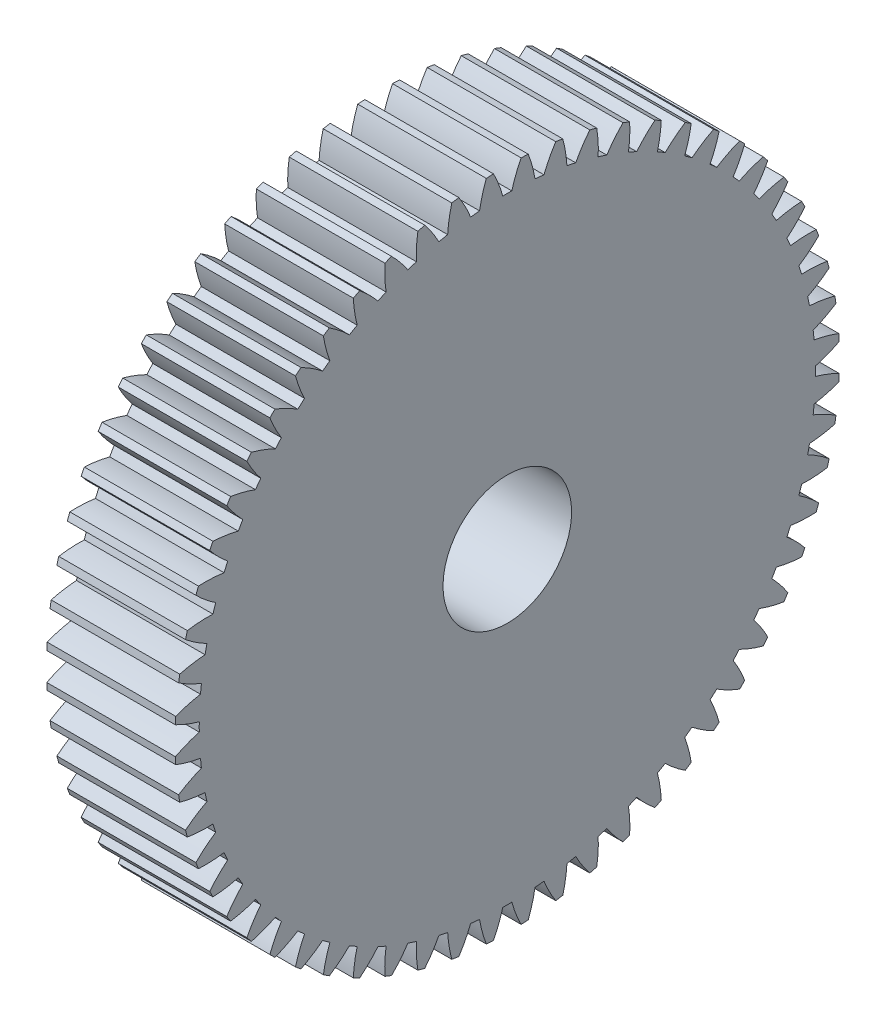
from build123d import *

# Parameters (mm, degrees)
BASPROSKE_W     = 3
BASPROSKE_H     = 7.75
TOOTHCUT_DEPTH  = 12.363318177
TEETHCUTS_COUNT = 60
TEETHCUTS_ANGLE = 354
BORSKE_R        = 1.5
BORE_DEPTH      = 50.0000508


with BuildPart() as part:
    # BasProSke → Base-Revolve (revolve)
    with BuildSketch(Plane(origin=(0, 0, 0), x_dir=(1, 0, 0), z_dir=(0, 1, 0)), mode=Mode.PRIVATE) as base_revolve_sk:
        with Locations((1.5, 3.875)):
            Rectangle(BASPROSKE_W, BASPROSKE_H)
    revolve(base_revolve_sk.sketch.rotate(Axis((-10, 0, 0), (1, 0, 0)), 180), axis=Axis((-10, 0, 0), (1, 0, 0)))

    # TooCutSke → ToothCut (cut, through all)
    with BuildSketch(Plane(origin=(0, 0, 0), x_dir=(0, 0, -1), z_dir=(1, 0, 0))):
        with BuildLine():
            ThreePointArc((0.104813565, 7.185735618), (0, 7.1865), (-0.104813565, 7.185735618))
            ThreePointArc((-0.104813565, 7.185735618), (-0.204722577, 7.482981855), (-0.335114208, 7.768175051))
            ThreePointArc((-0.335114208, 7.768175051), (0, 7.7754), (0.335114208, 7.768175051))
            ThreePointArc((0.335114208, 7.768175051), (0.204722577, 7.482981855), (0.104813565, 7.185735618))
        make_face()
    toothcut = extrude(amount=TOOTHCUT_DEPTH, mode=Mode.SUBTRACT)

    # TeethCuts: ToothCut ×60 about axis
    teethcuts_axis = Axis((-10, 0, 0), (1, 0, 0))
    for i in range(1, TEETHCUTS_COUNT):
        add(toothcut.rotate(teethcuts_axis, i * TEETHCUTS_ANGLE / (TEETHCUTS_COUNT - 1)), mode=Mode.SUBTRACT)

    # BorSke → Bore (cut, symmetric)
    with BuildSketch(Plane(origin=(0, 0, 0), x_dir=(0, 0, -1), z_dir=(1, 0, 0))):
        with Locations(Location((0, 0, 0), (0, 0, 180))):
            Circle(BORSKE_R)
    extrude(amount=BORE_DEPTH, both=True, mode=Mode.SUBTRACT)


solid = part.part
